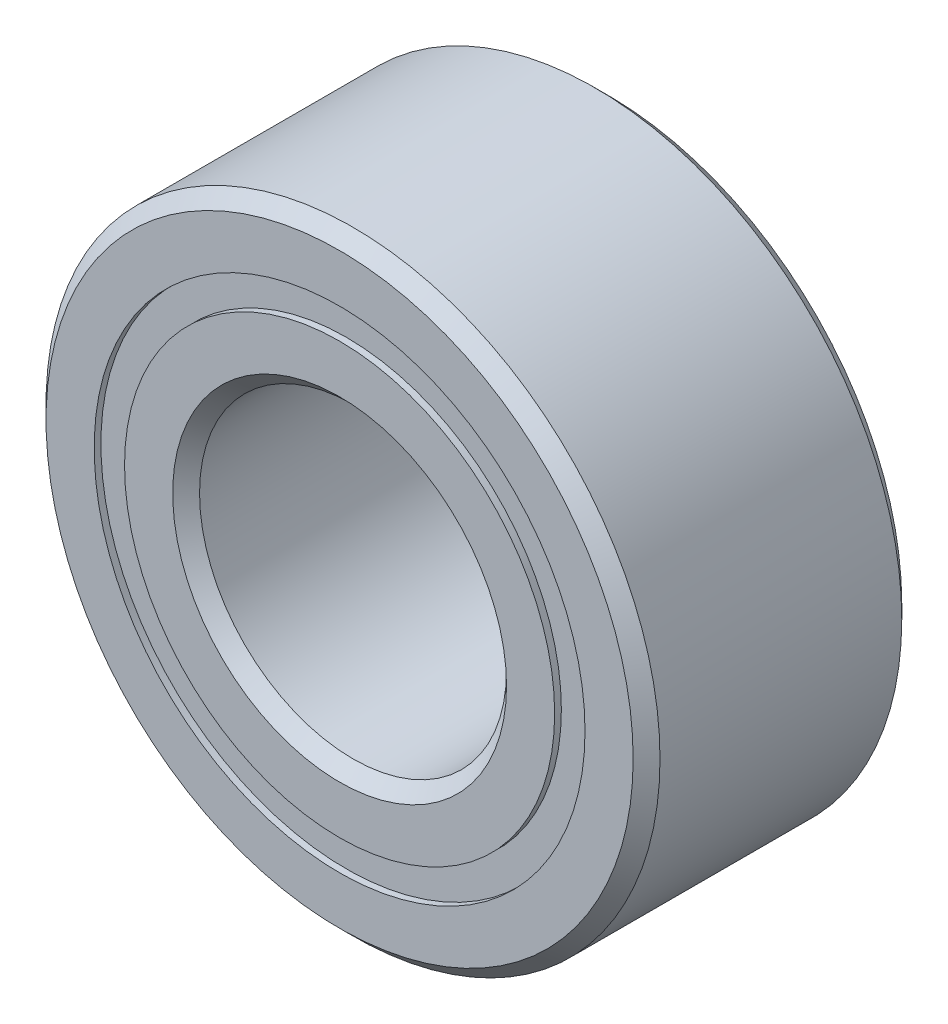
from build123d import *

# Parameters (mm, degrees)
CIRPATTERN1_COUNT = 10
SKETCH5_W         = 0.68259645
SKETCH5_H         = 0.31401099


with BuildPart() as part:
    # Sketch1 → Revolve1 (revolve)
    with BuildSketch(Plane(origin=(0, 0, 0), x_dir=(0, 0, -1), z_dir=(1, 0, 0))):
        with BuildLine():
            Line((1.25015625, 3.175), (-1.25015625, 3.175))
            Line((-1.25015625, 3.175), (-1.3890625, 3.03609375))
            Line((-1.3890625, 3.03609375), (-1.3890625, 2.538255495))
            Line((-1.3890625, 2.538255495), (-0.617361111, 2.538255495))
            ThreePointArc((-0.617361111, 2.538255495), (0, 3.018262925), (0.617361111, 2.538255495))
            Line((0.617361111, 2.538255495), (1.3890625, 2.538255495))
            Line((1.3890625, 2.538255495), (1.3890625, 3.03609375))
            Line((1.3890625, 3.03609375), (1.25015625, 3.175))
        make_face()
    revolve(axis=Axis((0, 0, 1.3890625), (0, 0, -1)))


with BuildPart() as body_2:
    # Sketch3 → Revolve3 (revolve)
    with BuildSketch(Plane(origin=(0, 0, 0), x_dir=(0, 0, -1), z_dir=(1, 0, 0))):
        with BuildLine():
            Line((-0.617361111, 2.224244505), (-1.3890625, 2.224244505))
            Line((-1.3890625, 2.224244505), (-1.3890625, 1.72640625))
            Line((-1.3890625, 1.72640625), (-1.25015625, 1.5875))
            Line((-1.25015625, 1.5875), (1.25015625, 1.5875))
            Line((1.25015625, 1.5875), (1.3890625, 1.72640625))
            Line((1.3890625, 1.72640625), (1.3890625, 2.224244505))
            Line((1.3890625, 2.224244505), (0.617361111, 2.224244505))
            ThreePointArc((0.617361111, 2.224244505), (0, 1.744237075), (-0.617361111, 2.224244505))
        make_face()
    revolve(axis=Axis((0, 0, 1.3890625), (0, 0, -1)))


with BuildPart() as body_3:
    # Sketch4 → Revolve4 (revolve)
    with BuildSketch(Plane(origin=(0, 0, 0), x_dir=(0, 0, -1), z_dir=(1, 0, 0))):
        with BuildLine():
            Line((-0.637012925, 2.38125), (0.637012925, 2.38125))
            ThreePointArc((0.637012925, 2.38125), (0, 3.018262925), (-0.637012925, 2.38125))
        make_face()
    revolve(axis=Axis((0, 2.38125, 0.637012925), (0, 0, -1)))


with BuildPart() as cirpattern1_1:
    # CirPattern1: pattern copy
    add(body_3.part.rotate(Axis((0, 0, 0), (0, 0, 1)), 1 * 360 / CIRPATTERN1_COUNT))


with BuildPart() as cirpattern1_2:
    # CirPattern1: pattern copy
    add(body_3.part.rotate(Axis((0, 0, 0), (0, 0, 1)), 2 * 360 / CIRPATTERN1_COUNT))


with BuildPart() as cirpattern1_3:
    # CirPattern1: pattern copy
    add(body_3.part.rotate(Axis((0, 0, 0), (0, 0, 1)), 3 * 360 / CIRPATTERN1_COUNT))


with BuildPart() as cirpattern1_4:
    # CirPattern1: pattern copy
    add(body_3.part.rotate(Axis((0, 0, 0), (0, 0, 1)), 4 * 360 / CIRPATTERN1_COUNT))


with BuildPart() as cirpattern1_5:
    # CirPattern1: pattern copy
    add(body_3.part.rotate(Axis((0, 0, 0), (0, 0, 1)), 5 * 360 / CIRPATTERN1_COUNT))


with BuildPart() as cirpattern1_6:
    # CirPattern1: pattern copy
    add(body_3.part.rotate(Axis((0, 0, 0), (0, 0, 1)), 6 * 360 / CIRPATTERN1_COUNT))


with BuildPart() as cirpattern1_7:
    # CirPattern1: pattern copy
    add(body_3.part.rotate(Axis((0, 0, 0), (0, 0, 1)), 7 * 360 / CIRPATTERN1_COUNT))


with BuildPart() as cirpattern1_8:
    # CirPattern1: pattern copy
    add(body_3.part.rotate(Axis((0, 0, 0), (0, 0, 1)), 8 * 360 / CIRPATTERN1_COUNT))


with BuildPart() as cirpattern1_9:
    # CirPattern1: pattern copy
    add(body_3.part.rotate(Axis((0, 0, 0), (0, 0, 1)), 9 * 360 / CIRPATTERN1_COUNT))


with BuildPart() as body_13:
    # Sketch5 → Revolve5 (revolve)
    with BuildSketch(Plane(origin=(0, 0, 0), x_dir=(0, 0, -1), z_dir=(1, 0, 0))):
        with Locations((-0.97831115, 2.38125)):
            Rectangle(SKETCH5_W, SKETCH5_H)
        with Locations((0.97831115, 2.38125)):
            Rectangle(SKETCH5_W, SKETCH5_H)
    revolve(axis=Axis((0, 0, 1.3890625), (0, 0, -1)))


solid = Compound([part.part, body_2.part, body_3.part, cirpattern1_1.part, cirpattern1_2.part, cirpattern1_3.part, cirpattern1_4.part, cirpattern1_5.part, cirpattern1_6.part, cirpattern1_7.part, cirpattern1_8.part, cirpattern1_9.part, body_13.part])
